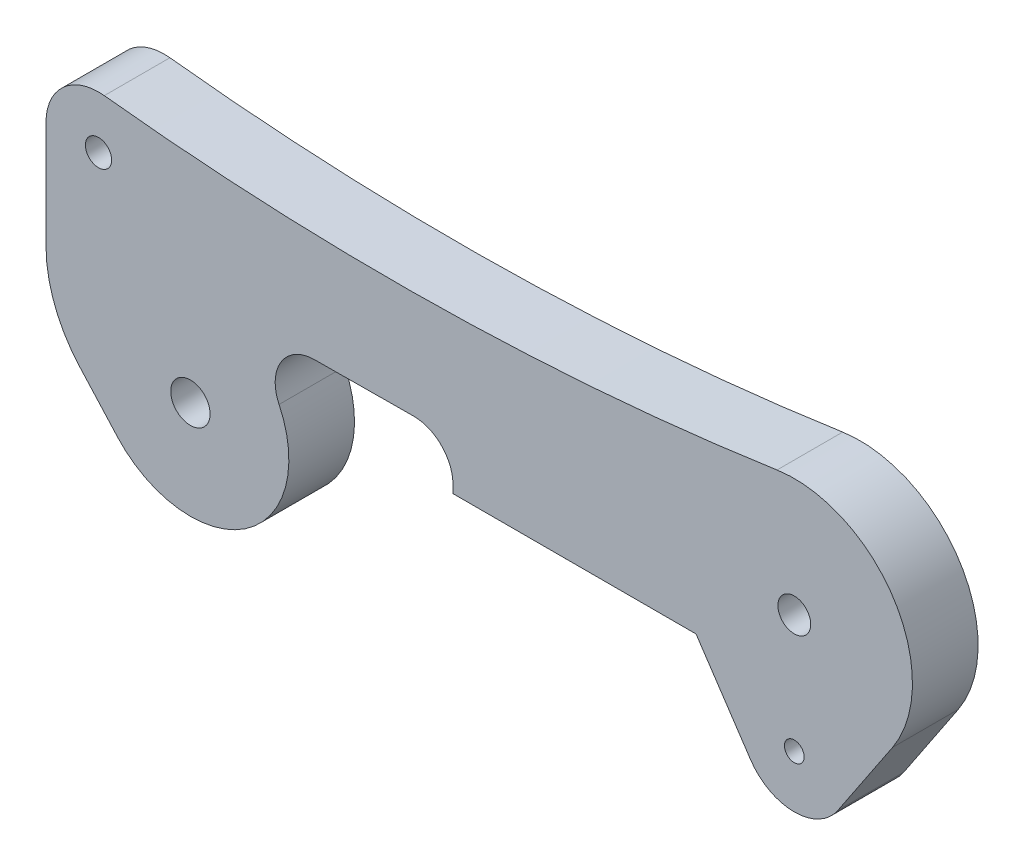
from build123d import *

# Parameters (mm, degrees)
SKETCH1_R           = 1.5
SKETCH1_R_2         = 0.75
SKETCH1_R_3         = 1.25
SKETCH1_R_4         = 1
BOSS_EXTRUDE1_DEPTH = 5


with BuildPart() as part:
    # Sketch1 → Boss-Extrude1 (new body)
    with BuildSketch(Plane.XY):
        with BuildLine():
            Line((53.483314774, 4), (49.325917677, -2.222222222))
            ThreePointArc((49.325917677, -2.222222222), (46, -4), (42.674082323, -2.222222222))
            Line((42.674082323, -2.222222222), (38.516685226, 4))
            Line((38.516685226, 4), (20, 4))
            Line((20, 4), (20, 4.615103075))
            ThreePointArc((20, 4.615103075), (19.114133272, 6.743586222), (16.979706327, 7.615034435))
            Line((16.979706327, 7.615034435), (9.43588174, 7.56400263))
            ThreePointArc((9.43588174, 7.56400263), (6.909923235, 6.150450748), (6.754411009, 3.260050907))
            ThreePointArc((6.754411009, 3.260050907), (4.183258191, -6.224977984), (-5.570203117, -5.022234287))
            Line((-5.570203117, -5.022234287), (-8.426937489, -1.853805696))
            ThreePointArc((-8.426937489, -1.853805696), (-10.334596266, 1.25568183), (-11, 4.842506687))
            Line((-11, 4.842506687), (-11, 13))
            ThreePointArc((-11, 13), (-9.66809518, 15.980145652), (-6.559365945, 16.975656126))
            ThreePointArc((-6.559365945, 16.975656126), (19.092866868, 15.791235692), (44.685411632, 17.903474458))
            ThreePointArc((44.685411632, 17.903474458), (53.605257844, 13.812489287), (53.483314774, 4))
        make_face()
        Circle(SKETCH1_R, mode=Mode.SUBTRACT)
        with Locations((46, 0)):
            Circle(SKETCH1_R_2, mode=Mode.SUBTRACT)
        with Locations((46, 9)):
            Circle(SKETCH1_R_3, mode=Mode.SUBTRACT)
        with Locations((-7, 13)):
            Circle(SKETCH1_R_4, mode=Mode.SUBTRACT)
    extrude(amount=BOSS_EXTRUDE1_DEPTH)


solid = part.part
